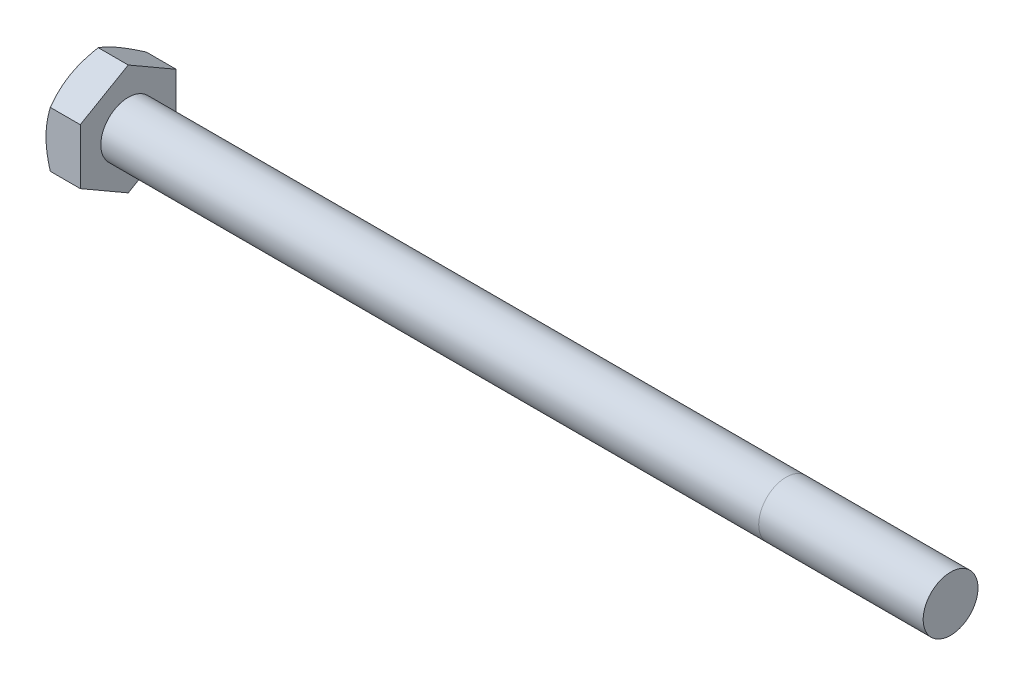
from build123d import *

# Parameters (mm, degrees)
SKETCH5_R           = 3.175
BOSS_EXTRUDE3_DEPTH = 95.25
BOSS_EXTRUDE4_DEPTH = 3.96875
SKETCH8_OUTSIDE_W   = 380.412
SKETCH8_OUTSIDE_H   = 382.132
SKETCH8_OUTSIDE_R   = 5.55625
CUT_EXTRUDE3_DEPTH  = 100.21875
CUT_EXTRUDE3_TAPER  = 60
CUT_EXTRUDE4_DEPTH  = 0.254
CIRPATTERN1_COUNT   = 3


with BuildPart() as part:
    # Sketch5 → Boss-Extrude3 (new body)
    with BuildSketch(Plane(origin=(49.609375, 0, 0), x_dir=(0, 0, -1), z_dir=(1, 0, 0))):
        Circle(SKETCH5_R)
    extrude(amount=-BOSS_EXTRUDE3_DEPTH)

    # Sketch11 → Revolve1 (revolve)
    with BuildSketch(Plane.XY):
        Polygon((-45.640625, 3.175), (-45.640625, 0), (33.734375, 0), (30.559375, 3.175), align=None)
    revolve(axis=Axis((-45.640625, 0, 0), (1, 0, 0)))

    # Sketch6 → Boss-Extrude4 (add)
    with BuildSketch(Plane.ZY.offset(45.640625)):
        Polygon((5.55625, 3.207902433), (0, 6.415804866), (-5.55625, 3.207902433), (-5.55625, -3.207902433), (0, -6.415804866), (5.55625, -3.207902433), align=None)
    extrude(amount=BOSS_EXTRUDE4_DEPTH)

    # Sketch8 outside → Cut-Extrude3 (cut, through all)
    with BuildSketch(Plane.ZY.offset(49.609375)):
        Rectangle(SKETCH8_OUTSIDE_W, SKETCH8_OUTSIDE_H)
        Circle(SKETCH8_OUTSIDE_R, mode=Mode.SUBTRACT)
    extrude(amount=-CUT_EXTRUDE3_DEPTH, taper=CUT_EXTRUDE3_TAPER, mode=Mode.SUBTRACT)

    # Sketch12 → Cut-Extrude4 (cut)
    with BuildSketch(Plane.ZY.offset(49.609375)):
        with BuildLine():
            Line((0.1666875, 4.2783125), (0.1666875, 2.3891875))
            ThreePointArc((0.1666875, 2.3891875), (0, 2.2225), (-0.1666875, 2.3891875))
            Line((-0.1666875, 2.3891875), (-0.1666875, 4.2783125))
            ThreePointArc((-0.1666875, 4.2783125), (0, 4.445), (0.1666875, 4.2783125))
        make_face()
    cut_extrude4 = extrude(amount=-CUT_EXTRUDE4_DEPTH, mode=Mode.SUBTRACT)

    # CirPattern1: Cut-Extrude4 ×3 about axis
    cirpattern1_axis = Axis((0, 0, 0), (1, 0, 0))
    for i in range(1, CIRPATTERN1_COUNT):
        add(cut_extrude4.rotate(cirpattern1_axis, i * 360 / CIRPATTERN1_COUNT), mode=Mode.SUBTRACT)


solid = part.part
